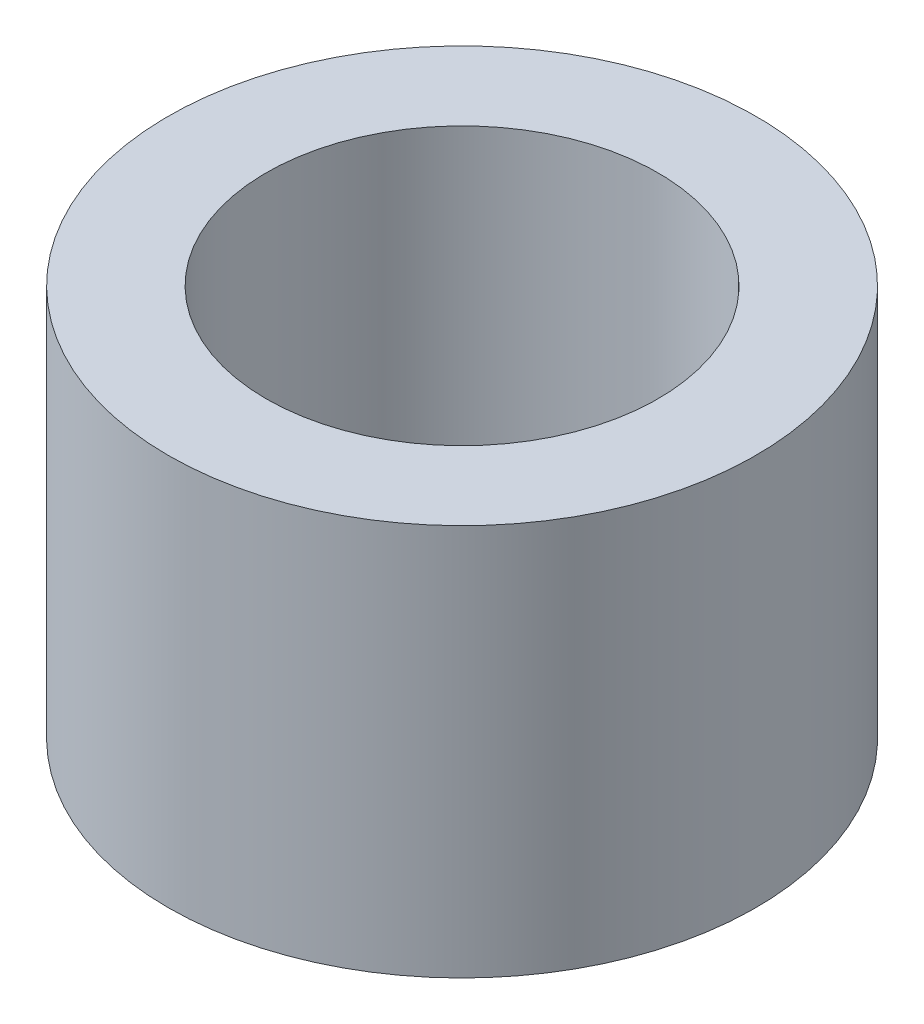
from build123d import *

# Parameters (mm, degrees)
SKETCH1_W = 1.5875
SKETCH1_H = 6.35


with BuildPart() as part:
    # Sketch1 → Revolve1 (revolve)
    with BuildSketch(Plane.XY):
        with Locations((-3.96875, 0)):
            Rectangle(SKETCH1_W, SKETCH1_H)
    revolve(axis=Axis((0, 3.175, 0), (0, -1, 0)))


solid = part.part
